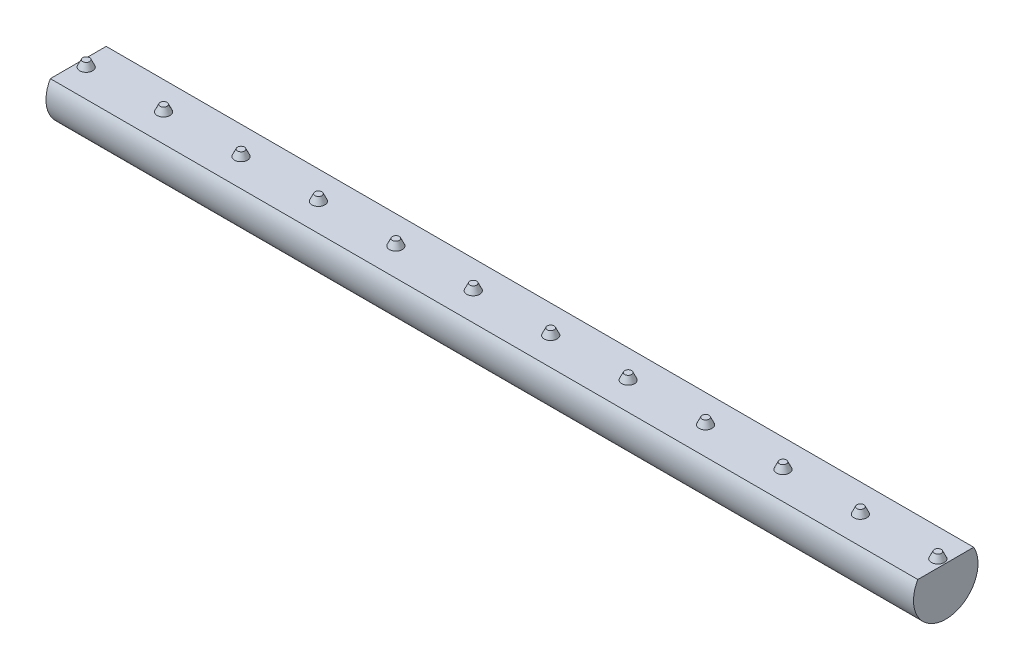
from build123d import *

# Parameters (mm, degrees)
AUFSATZ_LINEAR_AUSTRAGEN1_DEPTH = 134.46
SKIZZE3_R                       = 1
AUFSATZ_LINEAR_AUSTRAGEN2_DEPTH = 1
AUFSATZ_LINEAR_AUSTRAGEN2_TAPER = 25
LINEARES_MUSTER2_COUNT          = 12
LINEARES_MUSTER2_PITCH          = 12


with BuildPart() as part:
    # Skizze1 → Aufsatz-Linear austragen1 (new body)
    with BuildSketch(Plane(origin=(0, 0, 0), x_dir=(0, 0, -1), z_dir=(1, 0, 0))):
        with BuildLine():
            Line((-4.330127019, 2.5), (4.330127019, 2.5))
            ThreePointArc((4.330127019, 2.5), (0, -5), (-4.330127019, 2.5))
        make_face()
    extrude(amount=AUFSATZ_LINEAR_AUSTRAGEN1_DEPTH)

    # Skizze3 → Aufsatz-Linear austragen2 (add)
    with BuildSketch(Plane(origin=(0, 2.5, 0), x_dir=(1, 0, 0), z_dir=(0, 1, 0))):
        with Locations((1.229, 0)):
            Circle(SKIZZE3_R)
    aufsatz_linear_austragen2 = extrude(amount=AUFSATZ_LINEAR_AUSTRAGEN2_DEPTH, taper=AUFSATZ_LINEAR_AUSTRAGEN2_TAPER)

    # Lineares Muster2: Aufsatz-Linear austragen2 ×12
    with Locations(*[(i * LINEARES_MUSTER2_PITCH, 0, 0) for i in range(1, LINEARES_MUSTER2_COUNT)]):
        add(aufsatz_linear_austragen2)


solid = part.part
